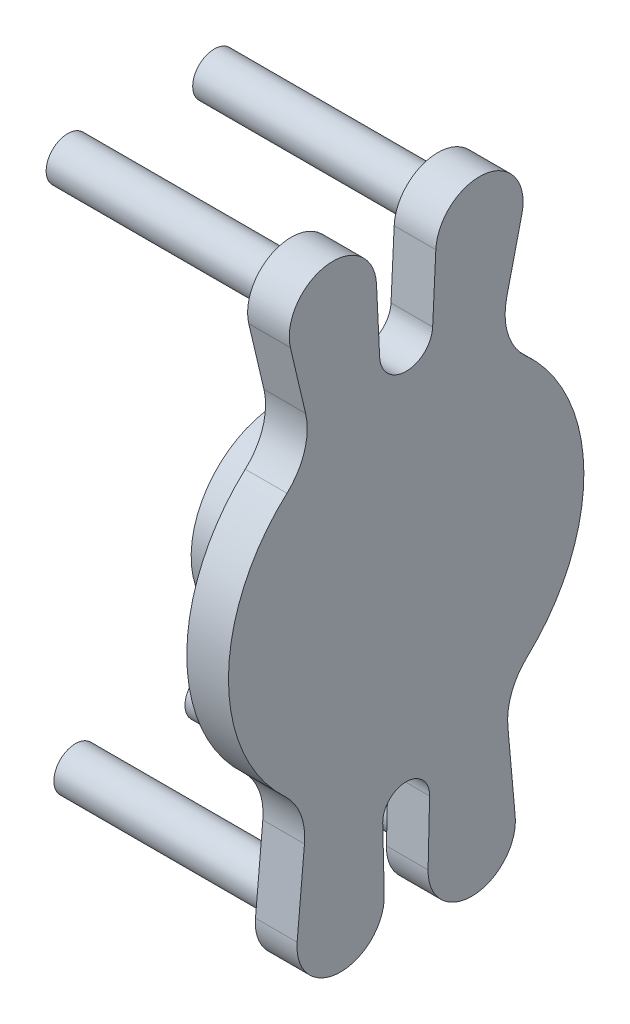
from build123d import *

# Parameters (mm, degrees)
SKETCH1_W           = 17.145
SKETCH1_H           = 18.542
SKETCH2_R           = 3.71475
CUT_EXTRUDE1_DEPTH  = 8.5725
BOSS_EXTRUDE1_DEPTH = 8.5725
SKETCH4_R           = 4.45
BOSS_EXTRUDE3_DEPTH = 46


with BuildPart() as part:
    # Sketch1 → Revolve1 (revolve)
    with BuildSketch(Plane.XY):
        with Locations((16.8275, 9.271)):
            Rectangle(SKETCH1_W, SKETCH1_H)
    revolve(axis=Axis((8.255, 0, 0), (1, 0, 0)))

    # Sketch2 → Cut-Extrude1 (cut)
    with BuildSketch(Plane.ZY.offset(-8.255)):
        Circle(SKETCH2_R)
    extrude(amount=-CUT_EXTRUDE1_DEPTH, mode=Mode.SUBTRACT)

    # Sketch3 → Boss-Extrude1 (add)
    with BuildSketch(Plane(origin=(25.4, 0, 0), x_dir=(0, 0, -1), z_dir=(1, 0, 0))):
        with BuildLine():
            Line((-20.702899344, 39.448323668), (-23.827032985, 52.708168154))
            ThreePointArc((-23.827032985, 52.708168154), (-16.334994998, 63.666100226), (-6.106605949, 55.205192121))
            Line((-6.106605949, 55.205192121), (-5.453270033, 41.770518865))
            ThreePointArc((-5.453270033, 41.770518865), (0, 36.576), (5.453270033, 41.770518865))
            Line((5.453270033, 41.770518865), (6.106605949, 55.205192121))
            ThreePointArc((6.106605949, 55.205192121), (16.334994998, 63.666100226), (23.827032985, 52.708168154))
            Line((23.827032985, 52.708168154), (20.702899344, 39.448323668))
            ThreePointArc((20.702899344, 39.448323668), (20.938893682, 32.759417922), (24.542669739, 27.119386757))
            ThreePointArc((24.542669739, 27.119386757), (36.575069792, 0.260855666), (24.926987696, -26.766566093))
            ThreePointArc((24.926987696, -26.766566093), (21.721471464, -31.520323876), (20.93336456, -37.199446597))
            Line((20.93336456, -37.199446597), (22.442795242, -53.962954235))
            ThreePointArc((22.442795242, -53.962954235), (13.789101844, -63.749144471), (4.511097805, -54.552701147))
            Line((4.511097805, -54.552701147), (4.824604712, -41.518040373))
            ThreePointArc((4.824604712, -41.518040373), (0, -36.576), (-4.824604712, -41.518040373))
            Line((-4.824604712, -41.518040373), (-4.511097805, -54.552701147))
            ThreePointArc((-4.511097805, -54.552701147), (-13.789101844, -63.749144471), (-22.442795242, -53.962954235))
            Line((-22.442795242, -53.962954235), (-20.93336456, -37.199446597))
            ThreePointArc((-20.93336456, -37.199446597), (-21.721471464, -31.520323876), (-24.926987696, -26.766566093))
            ThreePointArc((-24.926987696, -26.766566093), (-36.575069792, 0.260855666), (-24.542669739, 27.119386757))
            ThreePointArc((-24.542669739, 27.119386757), (-20.938893682, 32.759417922), (-20.702899344, 39.448323668))
        make_face()
    extrude(amount=BOSS_EXTRUDE1_DEPTH)

    # Sketch4 → Boss-Extrude3 (add)
    with BuildSketch(Plane.ZY.offset(-25.4)):
        with Locations((-15.08125, 54.76875)):
            Circle(SKETCH4_R)
        with Locations((15.08125, 54.76875)):
            Circle(SKETCH4_R)
        with Locations((-13.49375, -54.76875)):
            Circle(SKETCH4_R)
        with Locations((13.49375, -54.76875)):
            Circle(SKETCH4_R)
    extrude(amount=BOSS_EXTRUDE3_DEPTH)


solid = part.part
